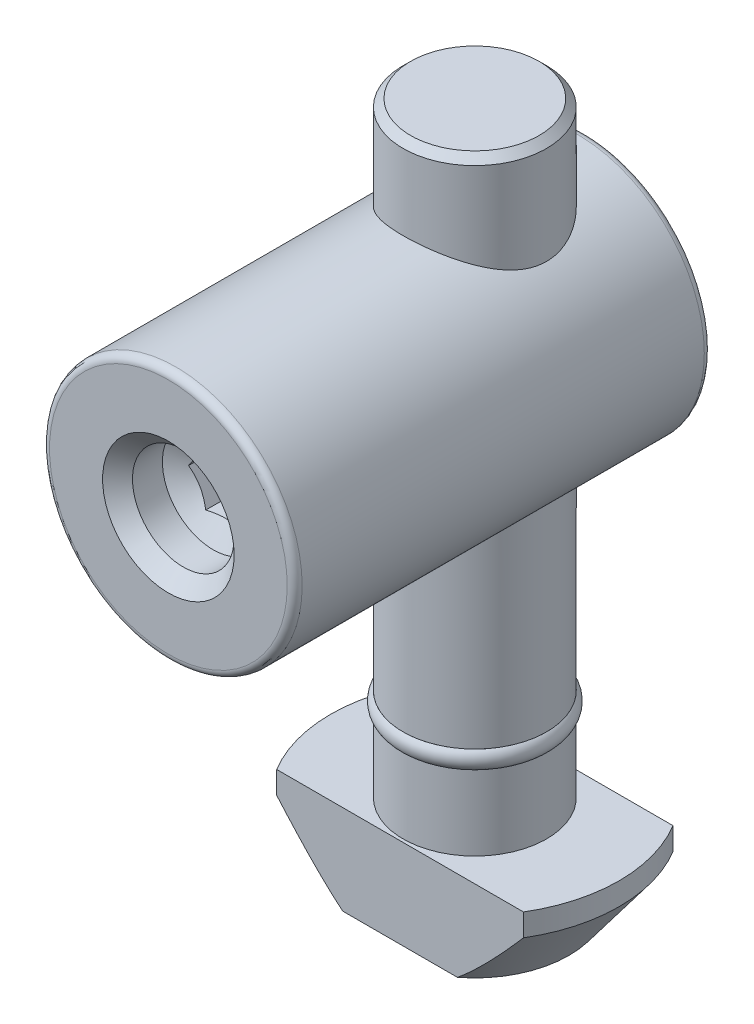
from build123d import *

# Parameters (mm, degrees)
SKETCH_6_OUTSIDE_W          = 32.084
SKETCH_6_OUTSIDE_H          = 32.084
SKETCH_6_OUTSIDE_W_2        = 19.3
SKETCH_6_OUTSIDE_H_2        = 10
CUT_EXTRUDE_1_DEPTH         = 6
CHAMFER_1_SIZE              = 0.5
SKETCH_12_R                 = 8.45
EXTRUDE_2_DEPTH             = 20.5
EXTRUDE_2_DEPTH_BACK        = 7.4
HOLE_WIZARD_M81_D           = 6.8
HOLE_WIZARD_M81_DEPTH       = 3
HOLE_WIZARD_M81_CSINK_D     = 8.8
HOLE_WIZARD_M81_CSINK_ANGLE = 90
HOLE_WIZARD_M81_TIP         = 2.042926105
FILLET_1_R                  = 0.5
CUT_EXTRUDE_2_DEPTH         = 6


with BuildPart() as part:
    # Эскиз3 → Повернуть1 (revolve)
    with BuildSketch(Plane.XY, mode=Mode.PRIVATE) as revolve_1_sk:
        Polygon((0, 0), (-4.8, 0), (-4.8, -34.3), (-4.3, -34.3), (-4.3, -35.5), (-4.8, -35.5), (-4.8, -40.5), (-9.65, -40.5), (-9.65, -42), (-6.3, -46.5), (0, -46.5), align=None)
    revolve(revolve_1_sk.sketch.rotate(Axis((0, 0, 0), (0, 1, 0)), 270), axis=Axis((0, 0, 0), (0, 1, 0)))  # turned: the seam where the file's is

    # Эскиз6 outside → Вырез-Вытянуть1 (cut)
    with BuildSketch(Plane.XZ.offset(46.5)):
        Rectangle(SKETCH_6_OUTSIDE_W, SKETCH_6_OUTSIDE_H)
        Rectangle(SKETCH_6_OUTSIDE_W_2, SKETCH_6_OUTSIDE_H_2, mode=Mode.SUBTRACT)
    extrude(amount=-CUT_EXTRUDE_1_DEPTH, mode=Mode.SUBTRACT)

    # Фаска1
    chamfer_1_edges = [part.edges().sort_by_distance(p)[0] for p in [
        (0, 0, 4.8),
    ]]
    chamfer(chamfer_1_edges, length=CHAMFER_1_SIZE)

    # Эскиз12 → Бобышка-Вытянуть2 (add, two sides)
    with BuildSketch(Plane.XY) as extrude_2_sk:
        with Locations((0, -14)):
            Circle(SKETCH_12_R)
    extrude(amount=EXTRUDE_2_DEPTH)
    extrude(extrude_2_sk.sketch, amount=-EXTRUDE_2_DEPTH_BACK)

    # Отверстие обработанное метчиком M81
    with Locations(Plane.XY.offset(20.5)):
        with Locations((0, -14)):
            CounterSinkHole(HOLE_WIZARD_M81_D / 2, HOLE_WIZARD_M81_CSINK_D / 2, depth=HOLE_WIZARD_M81_DEPTH, counter_sink_angle=HOLE_WIZARD_M81_CSINK_ANGLE)
            with Locations((0, 0, -(HOLE_WIZARD_M81_DEPTH + HOLE_WIZARD_M81_TIP / 2))):  # 118° drill point
                Cone(0, HOLE_WIZARD_M81_D / 2, HOLE_WIZARD_M81_TIP, mode=Mode.SUBTRACT)

    # Скругление1
    fillet_1_edges = [part.edges().sort_by_distance(p)[0] for p in [
        (-8.45, -14, -7.4),
        (-8.45, -14, 20.5),
    ]]
    fillet(fillet_1_edges, radius=FILLET_1_R)

    # Эскиз15 → Вырез-Вытянуть2 (cut)
    with BuildSketch(Plane.XY.offset(20.5)):
        Polygon((2.309401077, -14), (1.154700538, -12), (-1.154700538, -12), (-2.309401077, -14), (-1.154700538, -16), (1.154700538, -16), align=None)
    extrude(amount=-CUT_EXTRUDE_2_DEPTH, mode=Mode.SUBTRACT)


with BuildPart() as body_2:
    # Эскиз16 → Повернуть2 (revolve)
    with BuildSketch(Plane.XY, mode=Mode.PRIVATE) as revolve_2_sk:
        with BuildLine():
            Line((-4.3, -34.3), (-4.8, -34.3))
            ThreePointArc((-4.8, -34.3), (-5.081024968, -34.9), (-4.8, -35.5))
            Line((-4.8, -35.5), (-4.3, -35.5))
            Line((-4.3, -35.5), (-4.3, -34.3))
        make_face()
    revolve(revolve_2_sk.sketch.rotate(Axis((0, -34.3, 0), (0, -1, 0)), 90), axis=Axis((0, -34.3, 0), (0, -1, 0)))  # turned: the seam where the file's is


solid = Compound([part.part, body_2.part])
